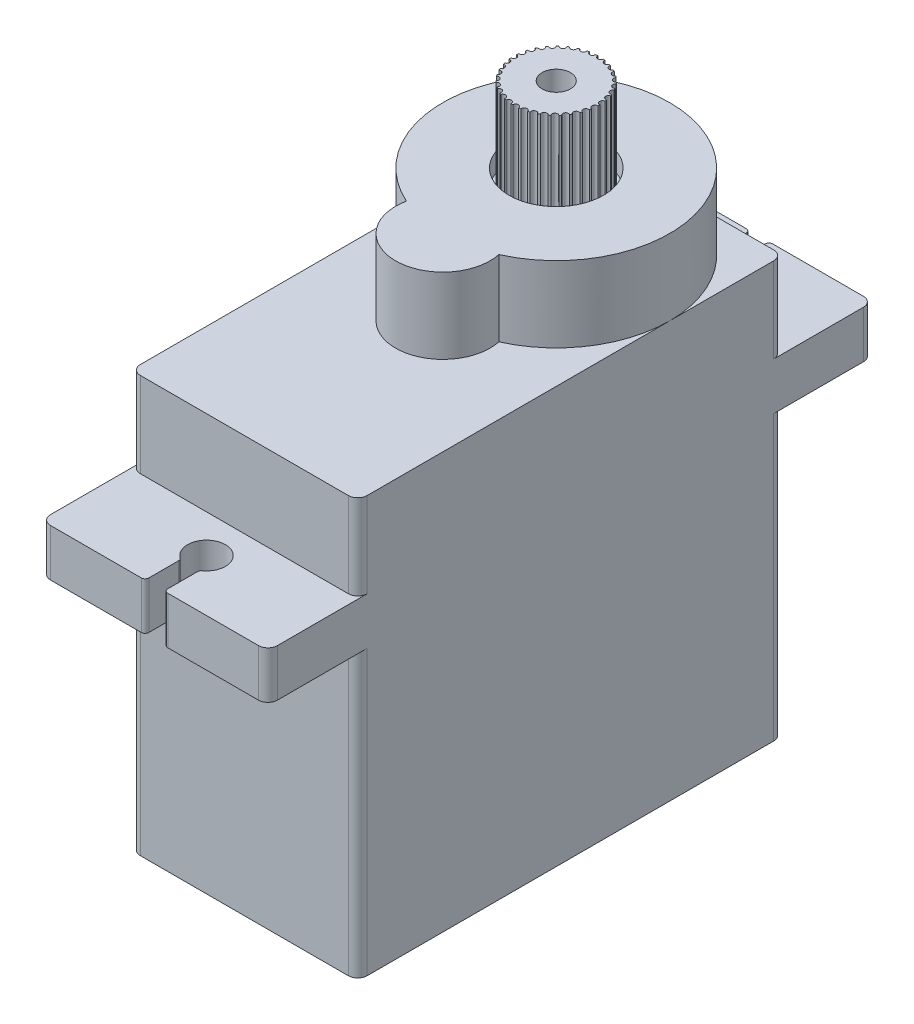
from build123d import *

# Parameters (mm, degrees)
Y_KSEKLIK_EKSTR_ZYON1_DEPTH  = 1
Y_KSEKLIK_EKSTR_ZYON2_DEPTH  = 5
IZIM3_W                      = 4
IZIM3_H                      = 1
KES_EKSTR_ZYON1_DEPTH        = 1
RADYUS1_R                    = 0.1
Y_KSEKLIK_EKSTR_ZYON4_DEPTH  = 9
Y_KSEKLIK_EKSTR_ZYON5_DEPTH  = 2.5
Y_KSEKLIK_EKSTR_ZYON6_DEPTH  = 3.5
Y_KSEKLIK_EKSTR_ZYON7_DEPTH  = 1
KES_EKSTR_ZYON2_DEPTH        = 1
Y_KSEKLIK_EKSTR_ZYON8_START  = 3
Y_KSEKLIK_EKSTR_ZYON8_DEPTH  = 3
RADYUS2_R                    = 0.5
Y_KSEKLIK_EKSTR_ZYON9_START  = 1
Y_KSEKLIK_EKSTR_ZYON9_DEPTH  = 1
IZIM11_R                     = 2.5
KES_EKSTR_ZYON3_DEPTH        = 10
IZIM15_R                     = 0.25
Y_KSEKLIK_EKSTR_ZYON12_DEPTH = 11
IZIM19_R                     = 2.25
Y_KSEKLIK_EKSTR_ZYON17_DEPTH = 5
IZIM20_R                     = 4.75
Y_KSEKLIK_EKSTR_ZYON18_DEPTH = 3
IZIM21_R                     = 0.75
KES_EKSTR_ZYON5_DEPTH        = 10
IZIM22_R                     = 0.5
Y_KSEKLIK_EKSTR_ZYON19_DEPTH = 5
IZIM23_R                     = 4
Y_KSEKLIK_EKSTR_ZYON20_DEPTH = 2
IZIM24_R                     = 0.75
Y_KSEKLIK_EKSTR_ZYON21_DEPTH = 7
IZIM25_R                     = 3.5
Y_KSEKLIK_EKSTR_ZYON22_DEPTH = 1
IZIM26_R                     = 4.5
Y_KSEKLIK_EKSTR_ZYON23_DEPTH = 1
KES_EKSTR_ZYON7_DEPTH        = 30
Y_KSEKLIK_EKSTR_ZYON33_DEPTH = 1
Y_KSEKLIK_EKSTR_ZYON34_DEPTH = 14
IZIM37_W                     = 8
IZIM37_H                     = 6
Y_KSEKLIK_EKSTR_ZYON36_DEPTH = 1
IZIM39_W                     = 4
IZIM39_H                     = 1
Y_KSEKLIK_EKSTR_ZYON37_DEPTH = 0.1
IZIM40_R                     = 0.4
Y_KSEKLIK_EKSTR_ZYON38_DEPTH = 2
IZIM41_R                     = 0.15
KES_EKSTR_ZYON8_DEPTH        = 5


with BuildPart() as part:
    # Çizim1 → Yükseklik-Ekstrüzyon1 (new body)
    with BuildSketch(Plane(origin=(0, 0, 0), x_dir=(1, 0, 0), z_dir=(0, 1, 0))):
        with BuildLine():
            Line((-5.5, 11.25), (5.5, 11.25))
            ThreePointArc((5.5, 11.25), (5.853553391, 11.103553391), (6, 10.75))
            Line((6, 10.75), (6, -10.75))
            ThreePointArc((6, -10.75), (5.853553391, -11.103553391), (5.5, -11.25))
            Line((5.5, -11.25), (-5.5, -11.25))
            ThreePointArc((-5.5, -11.25), (-5.853553391, -11.103553391), (-6, -10.75))
            Line((-6, -10.75), (-6, 10.75))
            ThreePointArc((-6, 10.75), (-5.853553391, 11.103553391), (-5.5, 11.25))
        make_face()
    extrude(amount=Y_KSEKLIK_EKSTR_ZYON1_DEPTH)

    # Çizim2 → Yükseklik-Ekstrüzyon2 (add)
    with BuildSketch(Plane(origin=(0, 1, 0), x_dir=(1, 0, 0), z_dir=(0, 1, 0))):
        with BuildLine():
            Line((-5.5, 11.25), (5.5, 11.25))
            ThreePointArc((5.5, 11.25), (5.853553391, 11.103553391), (6, 10.75))
            Line((6, 10.75), (6, -10.75))
            ThreePointArc((6, -10.75), (5.853553391, -11.103553391), (5.5, -11.25))
            Line((5.5, -11.25), (-5.5, -11.25))
            ThreePointArc((-5.5, -11.25), (-5.853553391, -11.103553391), (-6, -10.75))
            Line((-6, -10.75), (-6, 10.75))
            ThreePointArc((-6, 10.75), (-5.853553391, 11.103553391), (-5.5, 11.25))
        make_face()
        with BuildLine():
            Line((-5, 9.25), (-5, -9.25))
            ThreePointArc((-5, -9.25), (-4.292893219, -9.542893219), (-4, -10.25))
            Line((-4, -10.25), (4, -10.25))
            ThreePointArc((4, -10.25), (4.292893219, -9.542893219), (5, -9.25))
            Line((5, -9.25), (5, 9.25))
            ThreePointArc((5, 9.25), (4.292893219, 9.542893219), (4, 10.25))
            Line((4, 10.25), (-4, 10.25))
            ThreePointArc((-4, 10.25), (-4.292893219, 9.542893219), (-5, 9.25))
        make_face(mode=Mode.SUBTRACT)
    extrude(amount=Y_KSEKLIK_EKSTR_ZYON2_DEPTH)

    # Çizim3 → Kes-Ekstrüzyon1 (cut)
    with BuildSketch(Plane(origin=(0, 6, 0), x_dir=(1, 0, 0), z_dir=(0, 1, 0))):
        with Locations((0, -10.75)):
            Rectangle(IZIM3_W, IZIM3_H)
    extrude(amount=-KES_EKSTR_ZYON1_DEPTH, mode=Mode.SUBTRACT)

    # Radyus1
    radyus1_edges = [part.edges().sort_by_distance(p)[0] for p in [
        (2, 5, 10.75),
        (-2, 5, 10.75),
    ]]
    fillet(radyus1_edges, radius=RADYUS1_R)

    # Çizim4 → Yükseklik-Ekstrüzyon4 (add)
    with BuildSketch(Plane(origin=(0, 6, 0), x_dir=(1, 0, 0), z_dir=(0, 1, 0))):
        with BuildLine():
            Line((5.5, 11.25), (-5.5, 11.25))
            ThreePointArc((-5.5, 11.25), (-5.853553391, 11.103553391), (-6, 10.75))
            Line((-6, 10.75), (-6, -10.75))
            ThreePointArc((-6, -10.75), (-5.853553391, -11.103553391), (-5.5, -11.25))
            Line((-5.5, -11.25), (-2, -11.25))
            Line((-2, -11.25), (2, -11.25))
            Line((2, -11.25), (5.5, -11.25))
            ThreePointArc((5.5, -11.25), (5.853553391, -11.103553391), (6, -10.75))
            Line((6, -10.75), (6, 10.75))
            ThreePointArc((6, 10.75), (5.853553391, 11.103553391), (5.5, 11.25))
        make_face()
        with BuildLine():
            ThreePointArc((-5, 9.25), (-4.292893219, 9.542893219), (-4, 10.25))
            Line((-4, 10.25), (4, 10.25))
            ThreePointArc((4, 10.25), (4.292893219, 9.542893219), (5, 9.25))
            Line((5, 9.25), (5, -9.25))
            ThreePointArc((5, -9.25), (4.292893219, -9.542893219), (4, -10.25))
            Line((4, -10.25), (2, -10.25))
            Line((2, -10.25), (-2, -10.25))
            Line((-2, -10.25), (-4, -10.25))
            ThreePointArc((-4, -10.25), (-4.292893219, -9.542893219), (-5, -9.25))
            Line((-5, -9.25), (-5, 9.25))
        make_face(mode=Mode.SUBTRACT)
    extrude(amount=Y_KSEKLIK_EKSTR_ZYON4_DEPTH)

    # Çizim6 → Yükseklik-Ekstrüzyon5 (add)
    with BuildSketch(Plane(origin=(0, 15, 0), x_dir=(1, 0, 0), z_dir=(0, 1, 0))):
        with BuildLine():
            Line((-5.5, 16), (-0.7, 16))
            ThreePointArc((-0.7, 16), (-0.558578644, 15.941421356), (-0.5, 15.8))
            Line((-0.5, 15.8), (-0.5, 14.224679434))
            ThreePointArc((-0.5, 14.224679434), (-0.522048696, 14.133392342), (-0.583333333, 14.062232862))
            ThreePointArc((-0.583333333, 14.062232862), (0, 12.25), (0.583333333, 14.062232862))
            ThreePointArc((0.583333333, 14.062232862), (0.522048696, 14.133392342), (0.5, 14.224679434))
            Line((0.5, 14.224679434), (0.5, 15.8))
            ThreePointArc((0.5, 15.8), (0.558578644, 15.941421356), (0.7, 16))
            Line((0.7, 16), (5.5, 16))
            ThreePointArc((5.5, 16), (5.853553391, 15.853553391), (6, 15.5))
            Line((6, 15.5), (6, -15.5))
            ThreePointArc((6, -15.5), (5.853553391, -15.853553391), (5.5, -16))
            Line((5.5, -16), (0.7, -16))
            ThreePointArc((0.7, -16), (0.558578644, -15.941421356), (0.5, -15.8))
            Line((0.5, -15.8), (0.5, -14.224679434))
            ThreePointArc((0.5, -14.224679434), (0.522048696, -14.133392342), (0.583333333, -14.062232862))
            ThreePointArc((0.583333333, -14.062232862), (0, -12.25), (-0.583333333, -14.062232862))
            ThreePointArc((-0.583333333, -14.062232862), (-0.522048696, -14.133392342), (-0.5, -14.224679434))
            Line((-0.5, -14.224679434), (-0.5, -15.8))
            ThreePointArc((-0.5, -15.8), (-0.558578644, -15.941421356), (-0.7, -16))
            Line((-0.7, -16), (-5.5, -16))
            ThreePointArc((-5.5, -16), (-5.853553391, -15.853553391), (-6, -15.5))
            Line((-6, -15.5), (-6, 15.5))
            ThreePointArc((-6, 15.5), (-5.853553391, 15.853553391), (-5.5, 16))
        make_face()
        with BuildLine():
            Line((-4, 10.25), (4, 10.25))
            ThreePointArc((4, 10.25), (4.292893219, 9.542893219), (5, 9.25))
            Line((5, 9.25), (5, -9.25))
            ThreePointArc((5, -9.25), (4.292893219, -9.542893219), (4, -10.25))
            Line((4, -10.25), (-4, -10.25))
            ThreePointArc((-4, -10.25), (-4.292893219, -9.542893219), (-5, -9.25))
            Line((-5, -9.25), (-5, 9.25))
            ThreePointArc((-5, 9.25), (-4.292893219, 9.542893219), (-4, 10.25))
        make_face(mode=Mode.SUBTRACT)
    extrude(amount=Y_KSEKLIK_EKSTR_ZYON5_DEPTH)

    # Çizim7 → Yükseklik-Ekstrüzyon6 (add)
    with BuildSketch(Plane(origin=(0, 17.5, 0), x_dir=(1, 0, 0), z_dir=(0, 1, 0))):
        with BuildLine():
            Line((5.5, 11.25), (-5.5, 11.25))
            ThreePointArc((-5.5, 11.25), (-5.853553391, 11.103553391), (-6, 10.75))
            Line((-6, 10.75), (-6, -10.75))
            ThreePointArc((-6, -10.75), (-5.853553391, -11.103553391), (-5.5, -11.25))
            Line((-5.5, -11.25), (5.5, -11.25))
            ThreePointArc((5.5, -11.25), (5.853553391, -11.103553391), (6, -10.75))
            Line((6, -10.75), (6, 10.75))
            ThreePointArc((6, 10.75), (5.853553391, 11.103553391), (5.5, 11.25))
        make_face()
        with BuildLine():
            Line((-5, -9.25), (-5, 9.25))
            ThreePointArc((-5, 9.25), (-4.292893219, 9.542893219), (-4, 10.25))
            Line((-4, 10.25), (4, 10.25))
            ThreePointArc((4, 10.25), (4.292893219, 9.542893219), (5, 9.25))
            Line((5, 9.25), (5, -9.25))
            ThreePointArc((5, -9.25), (4.292893219, -9.542893219), (4, -10.25))
            Line((4, -10.25), (-4, -10.25))
            ThreePointArc((-4, -10.25), (-4.292893219, -9.542893219), (-5, -9.25))
        make_face(mode=Mode.SUBTRACT)
    extrude(amount=Y_KSEKLIK_EKSTR_ZYON6_DEPTH)

    # Çizim8 → Yükseklik-Ekstrüzyon7 (add)
    with BuildSketch(Plane(origin=(0, 21, 0), x_dir=(1, 0, 0), z_dir=(0, 1, 0))):
        with BuildLine():
            Line((-5.5, 11.25), (5.5, 11.25))
            ThreePointArc((5.5, 11.25), (5.853553391, 11.103553391), (6, 10.75))
            Line((6, 10.75), (6, -10.75))
            ThreePointArc((6, -10.75), (5.853553391, -11.103553391), (5.5, -11.25))
            Line((5.5, -11.25), (-5.5, -11.25))
            ThreePointArc((-5.5, -11.25), (-5.853553391, -11.103553391), (-6, -10.75))
            Line((-6, -10.75), (-6, 10.75))
            ThreePointArc((-6, 10.75), (-5.853553391, 11.103553391), (-5.5, 11.25))
        make_face()
    extrude(amount=Y_KSEKLIK_EKSTR_ZYON7_DEPTH)

    # Çizim9 → Kes-Ekstrüzyon2 (cut)
    with BuildSketch(Plane(origin=(0, 22, 0), x_dir=(1, 0, 0), z_dir=(0, 1, 0))):
        with BuildLine():
            ThreePointArc((1.015291078, 0.354166667), (0, 10.25), (-1.015291078, 0.354166667))
            ThreePointArc((-1.015291078, 0.354166667), (0, -2.25), (1.015291078, 0.354166667))
        make_face()
    extrude(amount=-KES_EKSTR_ZYON2_DEPTH, mode=Mode.SUBTRACT)

    # Çizim9<3> → Yükseklik-Ekstrüzyon8 (add)
    with BuildSketch(Plane(origin=(0, 22, 0), x_dir=(1, 0, 0), z_dir=(0, 1, 0)).offset(Y_KSEKLIK_EKSTR_ZYON8_START)):
        with BuildLine():
            ThreePointArc((2.445144707, -0.229166667), (0, 11.25), (-2.445144707, -0.229166667))
            ThreePointArc((-2.445144707, -0.229166667), (0, -3.25), (2.445144707, -0.229166667))
        make_face()
        with BuildLine():
            ThreePointArc((1.015291078, 0.354166667), (0, 10.25), (-1.015291078, 0.354166667))
            ThreePointArc((-1.015291078, 0.354166667), (0, -2.25), (1.015291078, 0.354166667))
        make_face(mode=Mode.SUBTRACT)
    extrude(amount=-Y_KSEKLIK_EKSTR_ZYON8_DEPTH)

    # Radyus2
    radyus2_edges = [part.edges().sort_by_distance(p)[0] for p in [
        (1.015291078, 23, -0.354166667),
        (-1.015291078, 23, -0.354166667),
    ]]
    fillet(radyus2_edges, radius=RADYUS2_R)

    # Çizim10 → Yükseklik-Ekstrüzyon9 (add)
    with BuildSketch(Plane(origin=(0, 25, 0), x_dir=(1, 0, 0), z_dir=(0, 1, 0)).offset(Y_KSEKLIK_EKSTR_ZYON9_START)):
        with BuildLine():
            ThreePointArc((2.445144707, -0.229166667), (0, 11.25), (-2.445144707, -0.229166667))
            ThreePointArc((-2.445144707, -0.229166667), (0, -3.25), (2.445144707, -0.229166667))
        make_face()
    extrude(amount=-Y_KSEKLIK_EKSTR_ZYON9_DEPTH)

    # Çizim11 → Kes-Ekstrüzyon3 (cut)
    with BuildSketch(Plane(origin=(0, 26, 0), x_dir=(1, 0, 0), z_dir=(0, 1, 0))):
        with Locations((0, 5.25)):
            Circle(IZIM11_R)
    extrude(amount=-KES_EKSTR_ZYON3_DEPTH, mode=Mode.SUBTRACT)

    # Çizim15 → Yükseklik-Ekstrüzyon12 (add)
    with BuildSketch(Plane(origin=(0, 26, 0), x_dir=(1, 0, 0), z_dir=(0, 1, 0))):
        with Locations((0, -0.75)):
            Circle(IZIM15_R)
    extrude(amount=-Y_KSEKLIK_EKSTR_ZYON12_DEPTH)



with BuildPart() as body_2:
    # Çizim19 → Yükseklik-Ekstrüzyon17 (new body)
    with BuildSketch(Plane(origin=(0, 30, 0), x_dir=(1, 0, 0), z_dir=(0, 1, 0))):
        with Locations((0, 5.25)):
            Circle(IZIM19_R)
    extrude(amount=-Y_KSEKLIK_EKSTR_ZYON17_DEPTH)


with BuildPart() as part_1:
    add(part.part)

    add(body_2.part)  # Yükseklik-Ekstrüzyon18 merges body 2
    # Çizim20 → Yükseklik-Ekstrüzyon18 (add)
    with BuildSketch(Plane.XZ.offset(-25)):
        with Locations((0, -5.25)):
            Circle(IZIM20_R)
    extrude(amount=Y_KSEKLIK_EKSTR_ZYON18_DEPTH)

    # Çizim21 → Kes-Ekstrüzyon5 (cut)
    with BuildSketch(Plane(origin=(0, 30, 0), x_dir=(1, 0, 0), z_dir=(0, 1, 0))):
        with Locations((0, 5.25)):
            Circle(IZIM21_R)
    extrude(amount=-KES_EKSTR_ZYON5_DEPTH, mode=Mode.SUBTRACT)

    # Çizim22 → Yükseklik-Ekstrüzyon19 (add)
    with BuildSketch(Plane(origin=(0, 25.5, 0), x_dir=(1, 0, 0), z_dir=(0, 1, 0))):
        with Locations((0, -0.75)):
            Circle(IZIM22_R)
    extrude(amount=-Y_KSEKLIK_EKSTR_ZYON19_DEPTH)

    # Çizim23 → Yükseklik-Ekstrüzyon20 (add)
    with BuildSketch(Plane.XZ.offset(-20.5)):
        with Locations((0, 0.75)):
            Circle(IZIM23_R)
    extrude(amount=Y_KSEKLIK_EKSTR_ZYON20_DEPTH)

    # Çizim26 → Yükseklik-Ekstrüzyon23 (add)
    with BuildSketch(Plane(origin=(0, 17.5, 0), x_dir=(-1, 0, 0), z_dir=(0, -1, 0))):
        with Locations((0, -0.75)):
            Circle(IZIM26_R)
    extrude(amount=Y_KSEKLIK_EKSTR_ZYON23_DEPTH)

    # Çizim32 → Kes-Ekstrüzyon7 (cut)
    with BuildSketch(Plane(origin=(0, 0, 10.25), x_dir=(-1, 0, 0), z_dir=(0, 0, -1))):
        with BuildLine():
            Line((2, 6), (-2, 6))
            Line((-2, 6), (-2, 5.1))
            ThreePointArc((-2, 5.1), (-1.970710678, 5.029289322), (-1.9, 5))
            Line((-1.9, 5), (1.9, 5))
            ThreePointArc((1.9, 5), (1.970710678, 5.029289322), (2, 5.1))
            Line((2, 5.1), (2, 6))
        make_face()
    extrude(amount=KES_EKSTR_ZYON7_DEPTH, mode=Mode.SUBTRACT)

    # Çizim33 → Yükseklik-Ekstrüzyon33 (add)
    with BuildSketch(Plane.XY.offset(11.25)):
        with BuildLine():
            Line((-2, 6), (2, 6))
            Line((2, 6), (2, 5.1))
            ThreePointArc((2, 5.1), (1.970710678, 5.029289322), (1.9, 5))
            Line((1.9, 5), (-1.9, 5))
            ThreePointArc((-1.9, 5), (-1.970710678, 5.029289322), (-2, 5.1))
            Line((-2, 5.1), (-2, 6))
        make_face()
    extrude(amount=-Y_KSEKLIK_EKSTR_ZYON33_DEPTH)

    # Çizim34 → Yükseklik-Ekstrüzyon34 (add)
    with BuildSketch(Plane(origin=(0, 1, 0), x_dir=(1, 0, 0), z_dir=(0, 1, 0))):
        with BuildLine():
            Line((-3, -3.25), (3, -3.25))
            ThreePointArc((3, -3.25), (3.707106781, -3.542893219), (4, -4.25))
            Line((4, -4.25), (4, -8.25))
            ThreePointArc((4, -8.25), (3.707106781, -8.957106781), (3, -9.25))
            Line((3, -9.25), (-3, -9.25))
            ThreePointArc((-3, -9.25), (-3.707106781, -8.957106781), (-4, -8.25))
            Line((-4, -8.25), (-4, -4.25))
            ThreePointArc((-4, -4.25), (-3.707106781, -3.542893219), (-3, -3.25))
        make_face()
    extrude(amount=Y_KSEKLIK_EKSTR_ZYON34_DEPTH)

    # Çizim37 → Yükseklik-Ekstrüzyon36 (add)
    with BuildSketch(Plane(origin=(0, 1, 0), x_dir=(-1, 0, 0), z_dir=(0, -1, 0))):
        with Locations((0, -6.25)):
            Rectangle(IZIM37_W, IZIM37_H)
    extrude(amount=-Y_KSEKLIK_EKSTR_ZYON36_DEPTH)

    # Çizim39 → Yükseklik-Ekstrüzyon37 (add)
    with BuildSketch(Plane(origin=(0, 0, -10.75), x_dir=(-1, 0, 0), z_dir=(0, 0, -1))):
        with Locations((0, 5.514566781)):
            Rectangle(IZIM39_W, IZIM39_H)
    extrude(amount=Y_KSEKLIK_EKSTR_ZYON37_DEPTH)

    # Çizim40 → Yükseklik-Ekstrüzyon38 (add)
    with BuildSketch(Plane(origin=(0, 0, -10.85), x_dir=(-1, 0, 0), z_dir=(0, 0, -1))):
        with Locations((0, 5.55)):
            Circle(IZIM40_R)
        with Locations((1, 5.55)):
            Circle(IZIM40_R)
        with Locations((-1, 5.55)):
            Circle(IZIM40_R)
    extrude(amount=Y_KSEKLIK_EKSTR_ZYON38_DEPTH)

    # Çizim41 → Kes-Ekstrüzyon8 (cut)
    with BuildSketch(Plane(origin=(0, 30, 0), x_dir=(1, 0, 0), z_dir=(0, 1, 0))):
        with Locations((-2.25, 5.25)):
            Circle(IZIM41_R)
        with Locations((-2.213841574, 5.651753013)):
            Circle(IZIM41_R)
        with Locations((-2.213841574, 4.848246987)):
            Circle(IZIM41_R)
        with Locations((-2.106528459, 6.040593354)):
            Circle(IZIM41_R)
        with Locations((-2.106528459, 4.459406646)):
            Circle(IZIM41_R)
        with Locations((-1.931509786, 6.404023374)):
            Circle(IZIM41_R)
        with Locations((-1.931509786, 4.095976626)):
            Circle(IZIM41_R)
        with Locations((-1.694410799, 6.730362133)):
            Circle(IZIM41_R)
        with Locations((-1.694410799, 3.769637867)):
            Circle(IZIM41_R)
        with Locations((-1.402852054, 7.009120836)):
            Circle(IZIM41_R)
        with Locations((-1.402852054, 3.490879164)):
            Circle(IZIM41_R)
        with Locations((-1.066204491, 7.231339947)):
            Circle(IZIM41_R)
        with Locations((-1.066204491, 3.268660053)):
            Circle(IZIM41_R)
        with Locations((-0.695288237, 7.389877162)):
            Circle(IZIM41_R)
        with Locations((-0.695288237, 3.110122838)):
            Circle(IZIM41_R)
        with Locations((-0.302024848, 7.479636964)):
            Circle(IZIM41_R)
        with Locations((-0.302024848, 3.020363036)):
            Circle(IZIM41_R)
        with Locations((0.100945868, 7.4977344)):
            Circle(IZIM41_R)
        with Locations((0.100945868, 3.0022656)):
            Circle(IZIM41_R)
        with Locations((0.500672101, 7.443587802)):
            Circle(IZIM41_R)
        with Locations((0.500672101, 3.056412198)):
            Circle(IZIM41_R)
        with Locations((0.884306321, 7.318937488)):
            Circle(IZIM41_R)
        with Locations((0.884306321, 3.181062512)):
            Circle(IZIM41_R)
        with Locations((1.239518208, 7.127789821)):
            Circle(IZIM41_R)
        with Locations((1.239518208, 3.372210179)):
            Circle(IZIM41_R)
        with Locations((1.55489096, 6.876288444)):
            Circle(IZIM41_R)
        with Locations((1.55489096, 3.623711556)):
            Circle(IZIM41_R)
        with Locations((1.820288237, 6.572516818)):
            Circle(IZIM41_R)
        with Locations((1.820288237, 3.927483182)):
            Circle(IZIM41_R)
        with Locations((2.027179953, 6.226238413)):
            Circle(IZIM41_R)
        with Locations((2.027179953, 4.273761587)):
            Circle(IZIM41_R)
        with Locations((2.168916437, 5.848582903)):
            Circle(IZIM41_R)
        with Locations((2.168916437, 4.651417097)):
            Circle(IZIM41_R)
        with Locations((2.240942161, 5.451688445)):
            Circle(IZIM41_R)
        with Locations((2.240942161, 5.048311555)):
            Circle(IZIM41_R)
    extrude(amount=-KES_EKSTR_ZYON8_DEPTH, mode=Mode.SUBTRACT)


with BuildPart() as body_2_2:
    # Çizim24 → Yükseklik-Ekstrüzyon21 (new body)
    with BuildSketch(Plane.XZ.offset(-22)):
        with Locations((0, -5.25)):
            Circle(IZIM24_R)
    extrude(amount=Y_KSEKLIK_EKSTR_ZYON21_DEPTH)

    # Çizim25 → Yükseklik-Ekstrüzyon22 (add)
    with BuildSketch(Plane(origin=(0, 19, 0), x_dir=(-1, 0, 0), z_dir=(0, -1, 0))):
        with Locations((0, 5.25)):
            Circle(IZIM25_R)
    extrude(amount=Y_KSEKLIK_EKSTR_ZYON22_DEPTH)


solid = Compound([part_1.part, body_2_2.part])
